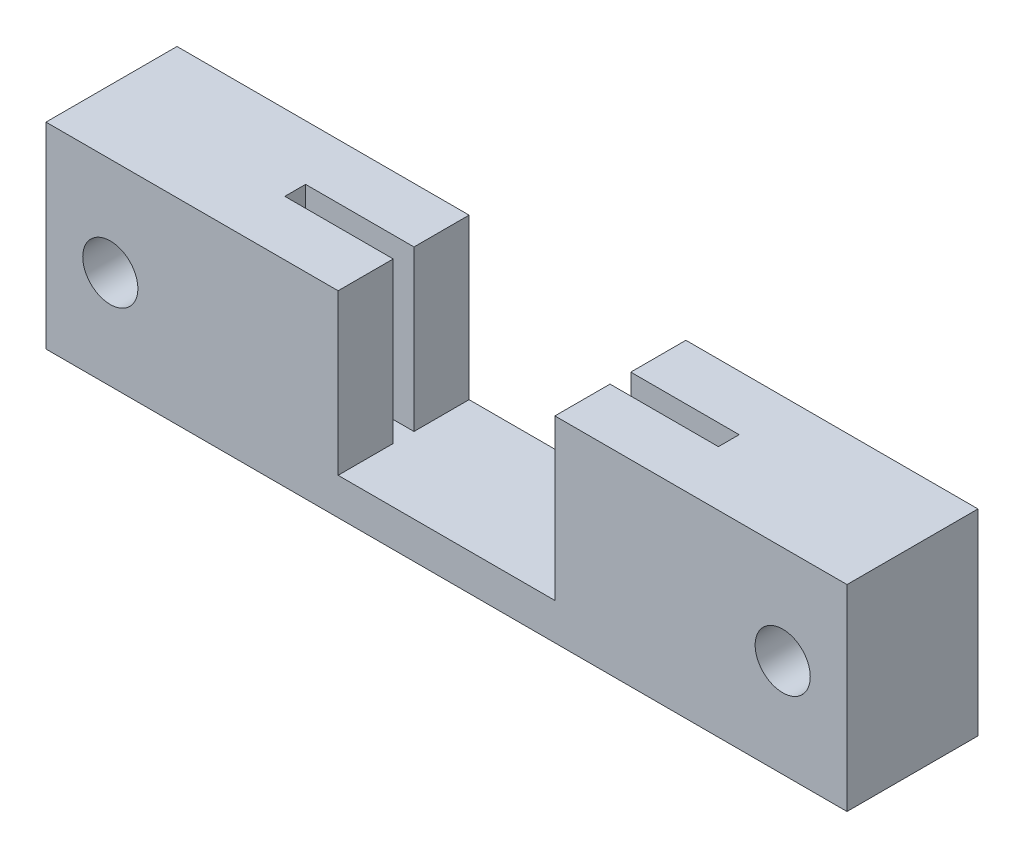
from build123d import *

# Parameters (mm, degrees)
BOSS_EXTRUDE1_DEPTH   = 8.7
BOSS_EXTRUDE1_2_DEPTH = 8.7
SKETCH3_W             = 29.6
SKETCH3_H             = 7.13
BOSS_EXTRUDE2_DEPTH   = 2
SKETCH4_W             = 7
SKETCH4_H             = 10.7
SKETCH4_R             = 1.5
BOSS_EXTRUDE3_DEPTH   = 7.13


with BuildPart() as part:
    # Sketch2 → Boss-Extrude1 (new body)
    with BuildSketch(Plane(origin=(0, 0, 0), x_dir=(1, 0, 0), z_dir=(0, 1, 0))):
        Polygon((-5.9, 3.565), (-5.9, 0.565), (-11.8, 0.565), (-11.8, -0.565), (-5.9, -0.565), (-5.9, -3.565), (-14.8, -3.565), (-14.8, 3.565), align=None)
    extrude(amount=BOSS_EXTRUDE1_DEPTH)



with BuildPart() as body_2:
    # Sketch2 → Boss-Extrude1 2 (new body)
    with BuildSketch(Plane(origin=(0, 0, 0), x_dir=(1, 0, 0), z_dir=(0, 1, 0))):
        Polygon((5.9, -0.565), (11.8, -0.565), (11.8, 0.565), (5.9, 0.565), (5.9, 3.565), (14.8, 3.565), (14.8, -3.565), (5.9, -3.565), align=None)
    extrude(amount=BOSS_EXTRUDE1_2_DEPTH)


with BuildPart() as part_1:
    add(part.part)

    add(body_2.part)  # Boss-Extrude2 merges body 2
    # Sketch3 → Boss-Extrude2 (add)
    with BuildSketch(Plane.XZ):
        Rectangle(SKETCH3_W, SKETCH3_H)
    extrude(amount=BOSS_EXTRUDE2_DEPTH)

    # Sketch4 → Boss-Extrude3 (add)
    with BuildSketch(Plane.XY.offset(3.565)):
        with Locations((18.3, 3.35)):
            Rectangle(SKETCH4_W, SKETCH4_H)
        with Locations((18.3, 3.35)):
            Circle(SKETCH4_R, mode=Mode.SUBTRACT)
        with Locations((-18.3, 3.35)):
            Rectangle(SKETCH4_W, SKETCH4_H)
        with Locations((-18.3, 3.35)):
            Circle(SKETCH4_R, mode=Mode.SUBTRACT)
    extrude(amount=-BOSS_EXTRUDE3_DEPTH)


solid = part_1.part
